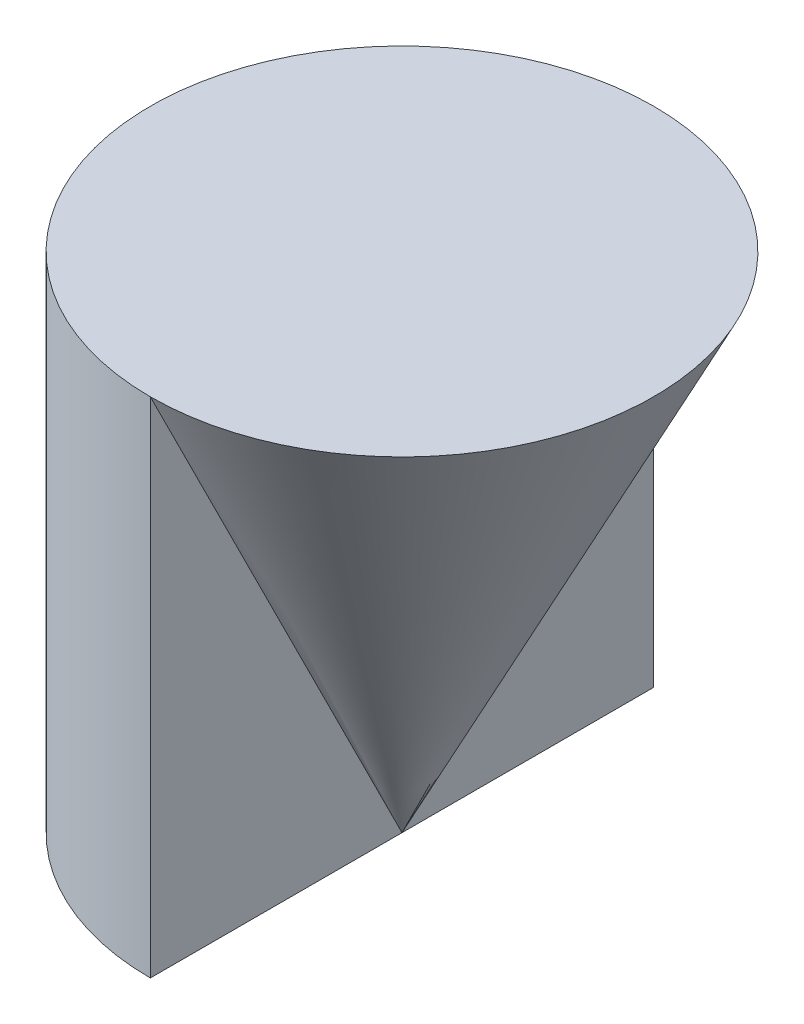
from build123d import *

# Parameters (mm, degrees)
BOSS_EXTRUDE1_DEPTH = 4
REVOLVE1_ANGLE      = 180


with BuildPart() as part:
    # Sketch1 → Boss-Extrude1 (new body)
    with BuildSketch(Plane(origin=(0, 0, 0), x_dir=(1, 0, 0), z_dir=(0, 1, 0))):
        with BuildLine():
            Line((0, 2), (0, -2))
            ThreePointArc((0, -2), (-2, 0), (0, 2))
        make_face()
    extrude(amount=BOSS_EXTRUDE1_DEPTH)

    # Sketch2 → Revolve1 (revolve)
    with BuildSketch(Plane(origin=(0, 0, 0), x_dir=(0, 0, -1), z_dir=(1, 0, 0))):
        Polygon((0, 0), (2, 4), (0, 4), align=None)
    revolve(axis=Axis((0, 4, 0), (0, -1, 0)), revolution_arc=REVOLVE1_ANGLE)


solid = part.part
